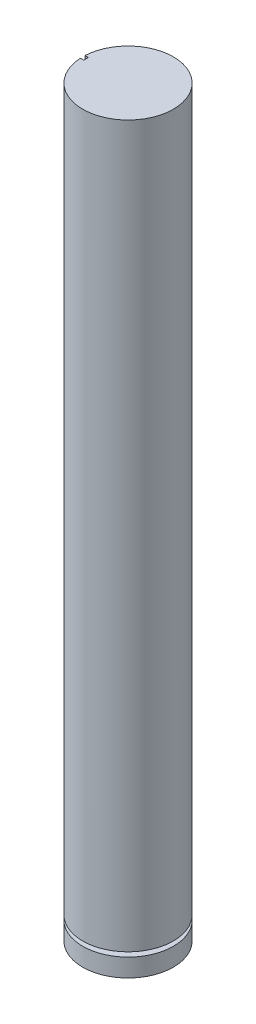
from build123d import *

# Parameters (mm, degrees)
SKETCH1_R           = 2
BOSS_EXTRUDE1_DEPTH = 32.766
SKETCH2_W           = 0.5
SKETCH2_H           = 0.2
SKETCH3_W           = 0.15
SKETCH3_H           = 0.2
CUT_EXTRUDE1_DEPTH  = 3


with BuildPart() as part:
    # Sketch1 → Boss-Extrude1 (new body)
    with BuildSketch(Plane(origin=(0, 0, 0), x_dir=(1, 0, 0), z_dir=(0, 1, 0))):
        Circle(SKETCH1_R)
    extrude(amount=BOSS_EXTRUDE1_DEPTH)

    # Sketch2 → Cut-Revolve1 (revolve, cut)
    with BuildSketch(Plane(origin=(0, 0, 0), x_dir=(0, 0, -1), z_dir=(1, 0, 0))):
        with Locations((1.75, 0.9)):
            Rectangle(SKETCH2_W, SKETCH2_H)
    revolve(axis=Axis((0, 0, 0), (0, 1, 0)), mode=Mode.SUBTRACT)

    # Sketch3 → Cut-Extrude1 (cut)
    with BuildSketch(Plane(origin=(0, 32.766, 0), x_dir=(1, 0, 0), z_dir=(0, 1, 0))):
        with Locations((-1.925, 0)):
            Rectangle(SKETCH3_W, SKETCH3_H)
    extrude(amount=-CUT_EXTRUDE1_DEPTH, mode=Mode.SUBTRACT)


solid = part.part
